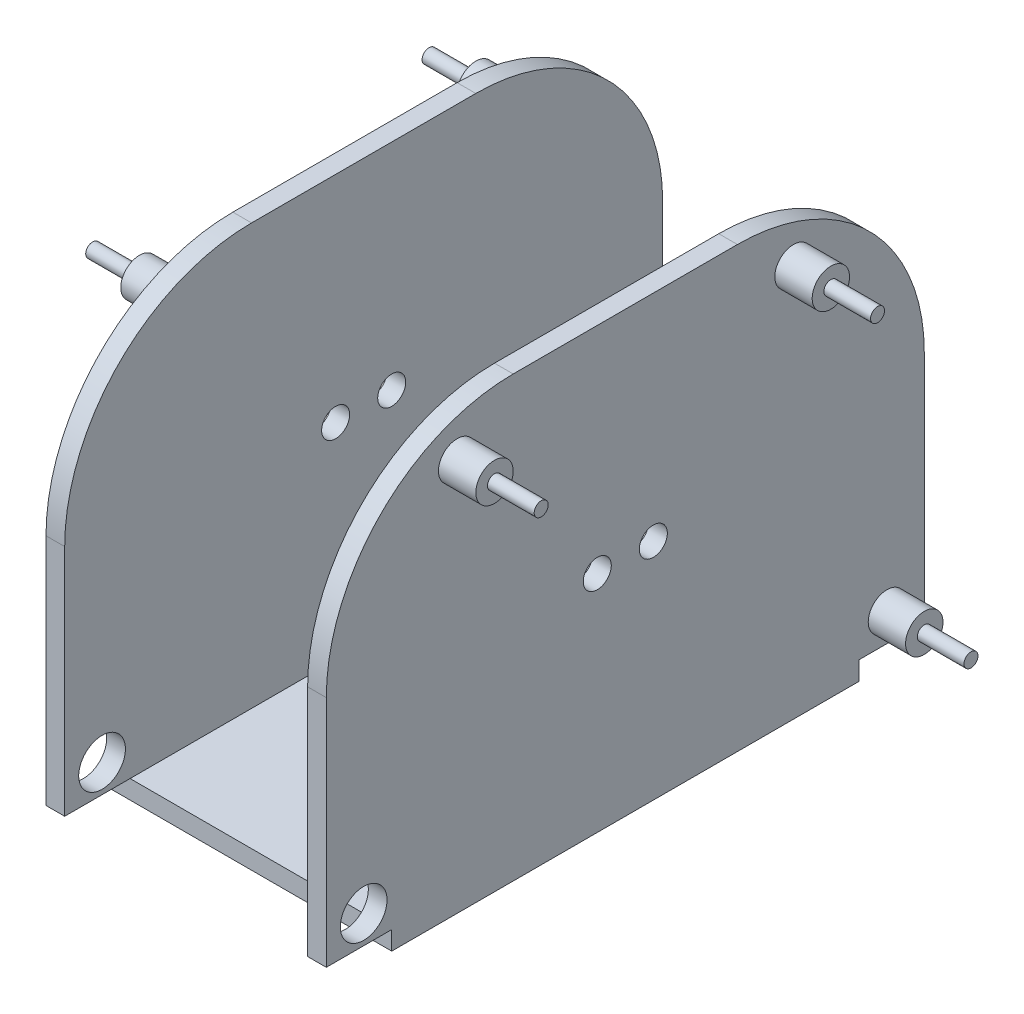
from build123d import *

# Parameters (mm, degrees)
SKETCH_1_W          = 30
SKETCH_1_H          = 50
EXTRUDE_1_DEPTH     = 2
SKETCH_3_W          = 2
SKETCH_3_H          = 64
EXTRUDE_2_DEPTH     = 45
SKETCH_6_R          = 2.5
CUT_EXTRUDE_1_DEPTH = 3
SKETCH_7_R          = 2
EXTRUDE_4_DEPTH     = 4
SKETCH_8_R          = 0.75
EXTRUDE_5_DEPTH     = 5
FILLET_1_R          = 20
SKETCH_9_R          = 1.5
CUT_EXTRUDE_2_DEPTH = 31
SKETCH_10_W         = 20
SKETCH_10_H         = 8
EXTRUDE_6_DEPTH     = 5


with BuildPart() as part:
    # 草图1 → 凸台-拉伸1 (new body)
    with BuildSketch(Plane(origin=(0, 0, 0), x_dir=(1, 0, 0), z_dir=(0, 1, 0))):
        Rectangle(SKETCH_1_W, SKETCH_1_H)
    extrude(amount=-EXTRUDE_1_DEPTH)

    # 草图3 → 凸台-拉伸2 (add)
    with BuildSketch(Plane(origin=(0, 0, 0), x_dir=(1, 0, 0), z_dir=(0, 1, 0))):
        with Locations((-14, 0)):
            Rectangle(SKETCH_3_W, SKETCH_3_H)
    extrude(amount=EXTRUDE_2_DEPTH)

    # 草图6 → 切除-拉伸1 (cut, through all)
    with BuildSketch(Plane(origin=(-13, 0, 0), x_dir=(0, 0, -1), z_dir=(1, 0, 0))):
        with Locations((-28, 3)):
            Circle(SKETCH_6_R)
    extrude(amount=-CUT_EXTRUDE_1_DEPTH, mode=Mode.SUBTRACT)

    # 草图7 → 凸台-拉伸4 (add)
    with BuildSketch(Plane.ZY.offset(15)):
        with Locations((-18, 40)):
            Circle(SKETCH_7_R)
        with Locations((18, 40)):
            Circle(SKETCH_7_R)
        with Locations((-28, 3)):
            Circle(SKETCH_7_R)
    extrude(amount=EXTRUDE_4_DEPTH)

    # 草图8 → 凸台-拉伸5 (add)
    with BuildSketch(Plane.ZY.offset(19)):
        with Locations((-18, 40)):
            Circle(SKETCH_8_R)
        with Locations((18, 40)):
            Circle(SKETCH_8_R)
        with Locations((-28, 3)):
            Circle(SKETCH_8_R)
    extrude(amount=EXTRUDE_5_DEPTH)

    # 圆角1
    fillet_1_edges = [part.edges().sort_by_distance(p)[0] for p in [
        (-14, 45, 32),
        (-14, 45, -32),
    ]]
    fillet(fillet_1_edges, radius=FILLET_1_R)

    # 草图9 → 切除-拉伸2 (cut, through all)
    with BuildSketch(Plane.ZY.offset(15)):
        with Locations((-3, 22)):
            Circle(SKETCH_9_R)
        with Locations((3, 22)):
            Circle(SKETCH_9_R)
    extrude(amount=-CUT_EXTRUDE_2_DEPTH, mode=Mode.SUBTRACT)

    # 镜向1: part across plane


with BuildPart() as part_1:
    add(part.part)
    add(part.part.mirror(Plane.ZY))

    # 草图10 → 凸台-拉伸6 (add)
    with BuildSketch(Plane(origin=(0, 0, 0), x_dir=(1, 0, 0), z_dir=(0, 1, 0))):
        with Locations((0, 6)):
            Rectangle(SKETCH_10_W, SKETCH_10_H)
    extrude(amount=EXTRUDE_6_DEPTH)


solid = part_1.part
